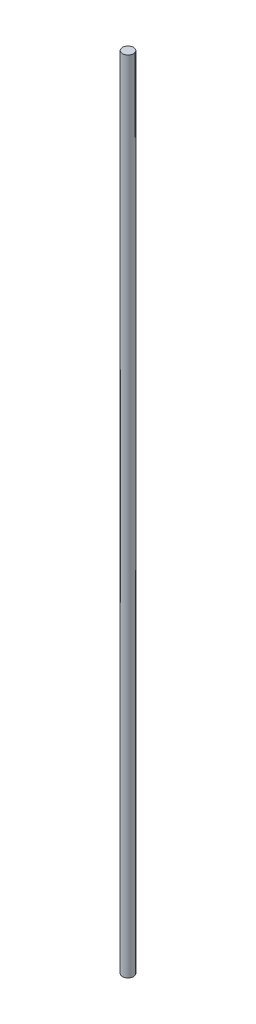
from build123d import *

# Parameters (mm, degrees)
SKETCH1_R           = 4
BOSS_EXTRUDE1_DEPTH = 580


with BuildPart() as part:
    # Sketch1 → Boss-Extrude1 (new body)
    with BuildSketch(Plane(origin=(0, 0, 0), x_dir=(1, 0, 0), z_dir=(0, 1, 0))):
        Circle(SKETCH1_R)
    extrude(amount=BOSS_EXTRUDE1_DEPTH)


solid = part.part
